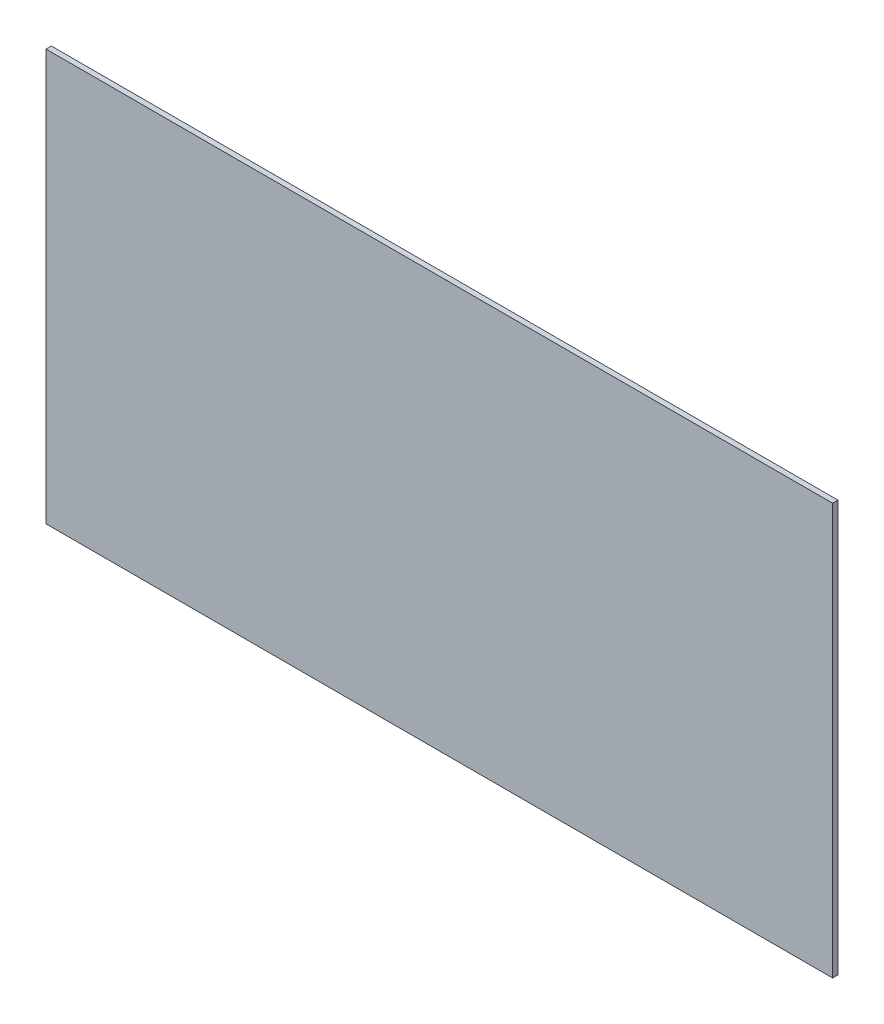
from build123d import *

# Parameters (mm, degrees)
CROQUIS1_W              = 440
CROQUIS1_H              = 230
SALIENTE_EXTRUIR1_DEPTH = 3


with BuildPart() as part:
    # Croquis1 → Saliente-Extruir1 (new body)
    with BuildSketch(Plane.XY):
        Rectangle(CROQUIS1_W, CROQUIS1_H)
    extrude(amount=SALIENTE_EXTRUIR1_DEPTH)


solid = part.part
